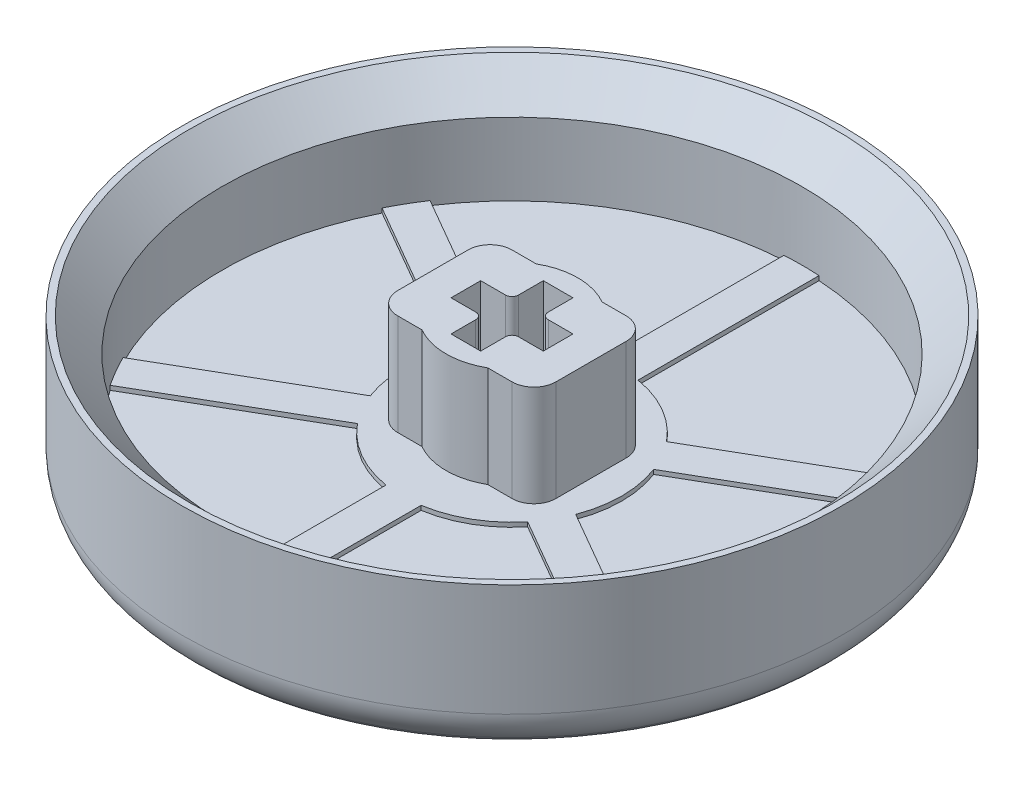
from build123d import *

# Parameters (mm, degrees)
SKETCH1_R          = 15
BUTTON_TOP_DEPTH   = 1.8
SKETCH2_R          = 15
SKETCH2_R_2        = 13.2
BUTTON_WALLS_DEPTH = 4.8
SKETCH5_R          = 5
OFFSET_2_DEPTH     = 0.2
STEM_START         = 0.2
STEM_HOUSING_DEPTH = 4.6
SPOKES_DEPTH       = 0.2
CHAMFER1_SIZE      = 1.5
FILLET2_R          = 1


with BuildPart() as part:
    # Sketch1 → button top (new body)
    with BuildSketch(Plane(origin=(0, 0, 0), x_dir=(1, 0, 0), z_dir=(0, 1, 0))):
        Circle(SKETCH1_R)
    extrude(amount=BUTTON_TOP_DEPTH)

    # Sketch2 → button walls (add)
    with BuildSketch(Plane(origin=(0, 1.8, 0), x_dir=(1, 0, 0), z_dir=(0, 1, 0))):
        Circle(SKETCH2_R)
        Circle(SKETCH2_R_2, mode=Mode.SUBTRACT)
    extrude(amount=BUTTON_WALLS_DEPTH)

    # Sketch5 → offset 2 (add)
    with BuildSketch(Plane(origin=(0, 1.8, 0), x_dir=(1, 0, 0), z_dir=(0, 1, 0))):
        Circle(SKETCH5_R)
    extrude(amount=OFFSET_2_DEPTH)

    # Sketch3 → stem housing (add)
    with BuildSketch(Plane(origin=(0, 1.8, 0), x_dir=(1, 0, 0), z_dir=(0, 1, 0)).offset(STEM_START)):
        with BuildLine():
            Line((-3.6, 2.6), (-3.6, -2.6))
            Line((-3.6, -2.6), (-1.496662955, -2.6))
            ThreePointArc((-1.496662955, -2.6), (-3, 0), (-1.496662955, 2.6))
            Line((-1.496662955, 2.6), (-3.6, 2.6))
        make_face()
        with BuildLine():
            ThreePointArc((-1.496662955, 2.6), (-3, 0), (-1.496662955, -2.6))
            Line((-1.496662955, -2.6), (1.496662955, -2.6))
            ThreePointArc((1.496662955, -2.6), (2.597112711, -1.501667596), (3, 0))
            ThreePointArc((3, 0), (2.597112711, 1.501667596), (1.496662955, 2.6))
            Line((1.496662955, 2.6), (-1.496662955, 2.6))
        make_face()
        with BuildLine():
            ThreePointArc((-0.975, 0.675), (-0.762867966, 0.762867966), (-0.675, 0.975))
            Line((-0.675, 0.975), (-0.675, 2.1))
            Line((-0.675, 2.1), (0.675, 2.1))
            Line((0.675, 2.1), (0.675, 0.975))
            ThreePointArc((0.675, 0.975), (0.762867966, 0.762867966), (0.975, 0.675))
            Line((0.975, 0.675), (2.1, 0.675))
            Line((2.1, 0.675), (2.1, -0.675))
            Line((2.1, -0.675), (0.975, -0.675))
            ThreePointArc((0.975, -0.675), (0.762867966, -0.762867966), (0.675, -0.975))
            Line((0.675, -0.975), (0.675, -2.1))
            Line((0.675, -2.1), (-0.675, -2.1))
            Line((-0.675, -2.1), (-0.675, -0.975))
            ThreePointArc((-0.675, -0.975), (-0.762867966, -0.762867966), (-0.975, -0.675))
            Line((-0.975, -0.675), (-2.1, -0.675))
            Line((-2.1, -0.675), (-2.1, 0.675))
            Line((-2.1, 0.675), (-0.975, 0.675))
        make_face(mode=Mode.SUBTRACT)
        with BuildLine():
            ThreePointArc((3, 0), (2.597112711, -1.501667596), (1.496662955, -2.6))
            Line((1.496662955, -2.6), (3.6, -2.6))
            Line((3.6, -2.6), (3.6, 2.6))
            Line((3.6, 2.6), (1.496662955, 2.6))
            ThreePointArc((1.496662955, 2.6), (2.597112711, 1.501667596), (3, 0))
        make_face()
        with BuildLine():
            ThreePointArc((1.496662955, 2.6), (0, 3), (-1.496662955, 2.6))
            Line((-1.496662955, 2.6), (1.496662955, 2.6))
        make_face()
        with BuildLine():
            Line((1.496662955, -2.6), (-1.496662955, -2.6))
            ThreePointArc((-1.496662955, -2.6), (0, -3), (1.496662955, -2.6))
        make_face()
    extrude(amount=STEM_HOUSING_DEPTH)

    # Sketch4 → spokes (add)
    with BuildSketch(Plane(origin=(0, 1.8, 0), x_dir=(1, 0, 0), z_dir=(0, 1, 0))):
        with BuildLine():
            Line((-0.8, 3.338167598), (-0.8, 13.2))
            ThreePointArc((-0.8, 13.2), (0, 14), (0.8, 13.2))
            Line((0.8, 13.2), (0.8, 3.338167598))
            ThreePointArc((0.8, 3.338167598), (0, 2.538167598), (-0.8, 3.338167598))
        make_face()
        with BuildLine():
            Line((2.490937942, 2.361904122), (11.03153533, 7.292820323))
            ThreePointArc((11.03153533, 7.292820323), (12.124355653, 7), (11.83153533, 5.907179677))
            Line((11.83153533, 5.907179677), (3.290937942, 0.976263476))
            ThreePointArc((3.290937942, 0.976263476), (2.198117619, 1.269083799), (2.490937942, 2.361904122))
        make_face()
        with BuildLine():
            Line((3.290937942, -0.976263476), (11.83153533, -5.907179677))
            ThreePointArc((11.83153533, -5.907179677), (12.124355653, -7), (11.03153533, -7.292820323))
            Line((11.03153533, -7.292820323), (2.490937942, -2.361904122))
            ThreePointArc((2.490937942, -2.361904122), (2.198117619, -1.269083799), (3.290937942, -0.976263476))
        make_face()
        with BuildLine():
            Line((0.8, -3.338167598), (0.8, -13.2))
            ThreePointArc((0.8, -13.2), (0, -14), (-0.8, -13.2))
            Line((-0.8, -13.2), (-0.8, -3.338167598))
            ThreePointArc((-0.8, -3.338167598), (0, -2.538167598), (0.8, -3.338167598))
        make_face()
        with BuildLine():
            Line((-2.490937942, -2.361904122), (-11.03153533, -7.292820323))
            ThreePointArc((-11.03153533, -7.292820323), (-12.124355653, -7), (-11.83153533, -5.907179677))
            Line((-11.83153533, -5.907179677), (-3.290937942, -0.976263476))
            ThreePointArc((-3.290937942, -0.976263476), (-2.198117619, -1.269083799), (-2.490937942, -2.361904122))
        make_face()
        with BuildLine():
            Line((-3.290937942, 0.976263476), (-11.83153533, 5.907179677))
            ThreePointArc((-11.83153533, 5.907179677), (-12.124355653, 7), (-11.03153533, 7.292820323))
            Line((-11.03153533, 7.292820323), (-2.490937942, 2.361904122))
            ThreePointArc((-2.490937942, 2.361904122), (-2.198117619, 1.269083799), (-3.290937942, 0.976263476))
        make_face()
    extrude(amount=SPOKES_DEPTH)

    # Chamfer1
    chamfer1_edges = [part.edges().sort_by_distance(p)[0] for p in [
        (-13.2, 6.6, 0),
    ]]
    chamfer(chamfer1_edges, length=CHAMFER1_SIZE)

    # Fillet2
    fillet2_edges = [part.edges().sort_by_distance(p)[0] for p in [
        (-3.6, 4.3, -2.6),
        (-3.6, 4.3, 2.6),
        (3.6, 4.3, 2.6),
        (3.6, 4.3, -2.6),
    ]]
    fillet(fillet2_edges, radius=FILLET2_R)

    # Sketch6 → Cut-Revolve1 (revolve, cut)
    with BuildSketch(Plane.XY):
        with BuildLine():
            Line((-14.261522369, 0), (-14.461522369, 0.2))
            ThreePointArc((-14.461522369, 0.2), (-14.860054223, 0.79644507), (-15, 1.5))
            Line((-15, 1.5), (-15, 0))
            Line((-15, 0), (-14.261522369, 0))
        make_face()
    revolve(axis=Axis((0, 0, 0), (0, 1, 0)), mode=Mode.SUBTRACT)


solid = part.part
